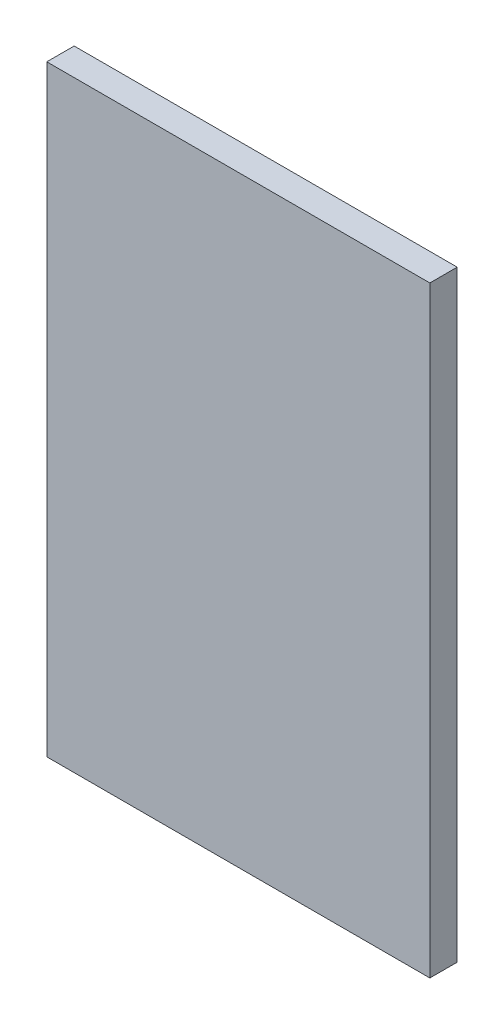
from build123d import *

# Parameters (mm, degrees)
SKETCH2_W           = 355.6
SKETCH2_H           = 558.8
BOSS_EXTRUDE1_DEPTH = 25.4


with BuildPart() as part:
    # Sketch2 → Boss-Extrude1 (new body)
    with BuildSketch(Plane.XY):
        Rectangle(SKETCH2_W, SKETCH2_H)
    extrude(amount=BOSS_EXTRUDE1_DEPTH)


solid = part.part
